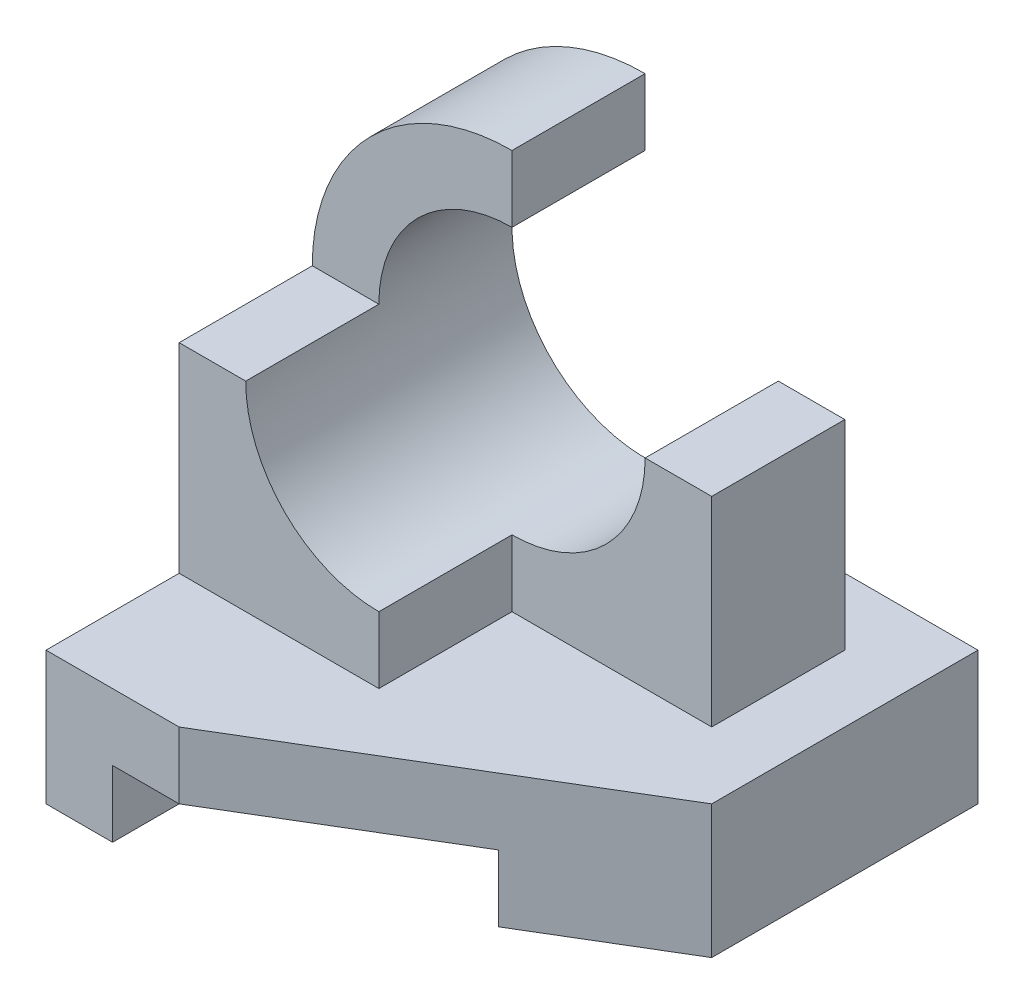
from build123d import *

# Parameters (mm, degrees)
SKETCH1_W           = 7
SKETCH1_H           = 2
BOSS_EXTRUDE1_DEPTH = 7
CUT_EXTRUDE1_DEPTH  = 3
SKETCH3_W           = 4
SKETCH3_H           = 1
CUT_EXTRUDE2_DEPTH  = 8
SKETCH4_W           = 3
SKETCH4_H           = 2
BOSS_EXTRUDE2_DEPTH = 3
BOSS_EXTRUDE4_DEPTH = 2
SKETCH7_R           = 2
CUT_EXTRUDE4_DEPTH  = 5


with BuildPart() as part:
    # Sketch1 → Boss-Extrude1 (new body)
    with BuildSketch(Plane.XY):
        Rectangle(SKETCH1_W, SKETCH1_H)
    extrude(amount=BOSS_EXTRUDE1_DEPTH)

    # Sketch2 → Cut-Extrude1 (cut, through all)
    with BuildSketch(Plane(origin=(0, 1, 0), x_dir=(1, 0, 0), z_dir=(0, 1, 0))):
        Polygon((3.5, -4), (-1.5, -7), (3.5, -7), align=None)
    extrude(amount=-CUT_EXTRUDE1_DEPTH, mode=Mode.SUBTRACT)

    # Sketch3 → Cut-Extrude2 (cut, through all)
    with BuildSketch(Plane.XY.offset(7)):
        with Locations((-0.5, -0.5)):
            Rectangle(SKETCH3_W, SKETCH3_H)
    extrude(amount=-CUT_EXTRUDE2_DEPTH, mode=Mode.SUBTRACT)

    # Sketch4 → Boss-Extrude2 (add)
    with BuildSketch(Plane(origin=(0, 1, 0), x_dir=(1, 0, 0), z_dir=(0, 1, 0))):
        with Locations((-2, -4)):
            Rectangle(SKETCH4_W, SKETCH4_H)
    extrude(amount=BOSS_EXTRUDE2_DEPTH)

    # Sketch6 → Boss-Extrude4 (add)
    with BuildSketch(Plane(origin=(0, 0, 3), x_dir=(-1, 0, 0), z_dir=(0, 0, -1))):
        with BuildLine():
            Line((0.5, 2), (0.5, 1))
            ThreePointArc((0.5, 1), (2.621320344, 1.878679656), (3.5, 4))
            Line((3.5, 4), (2.5, 4))
            ThreePointArc((2.5, 4), (1.914213562, 2.585786438), (0.5, 2))
        make_face()
        with BuildLine():
            Line((-2.5, 1), (0.5, 1))
            Line((0.5, 1), (0.5, 2))
            ThreePointArc((0.5, 2), (-0.914213562, 2.585786438), (-1.5, 4))
            Line((-1.5, 4), (-2.5, 4))
            Line((-2.5, 4), (-2.5, 1))
        make_face()
        with BuildLine():
            Line((2.5, 4), (3.5, 4))
            ThreePointArc((3.5, 4), (2.621320344, 6.121320344), (0.5, 7))
            Line((0.5, 7), (0.5, 6))
            ThreePointArc((0.5, 6), (1.914213562, 5.414213562), (2.5, 4))
        make_face()
        with BuildLine():
            ThreePointArc((3.5, 4), (2.621320344, 1.878679656), (0.5, 1))
            Line((0.5, 1), (3.5, 1))
            Line((3.5, 1), (3.5, 4))
        make_face()
    extrude(amount=BOSS_EXTRUDE4_DEPTH)

    # Sketch7 → Cut-Extrude4 (cut)
    with BuildSketch(Plane(origin=(0, 0, 1), x_dir=(-1, 0, 0), z_dir=(0, 0, -1))):
        with Locations((0.5, 4)):
            Circle(SKETCH7_R)
    extrude(amount=-CUT_EXTRUDE4_DEPTH, mode=Mode.SUBTRACT)


solid = part.part
